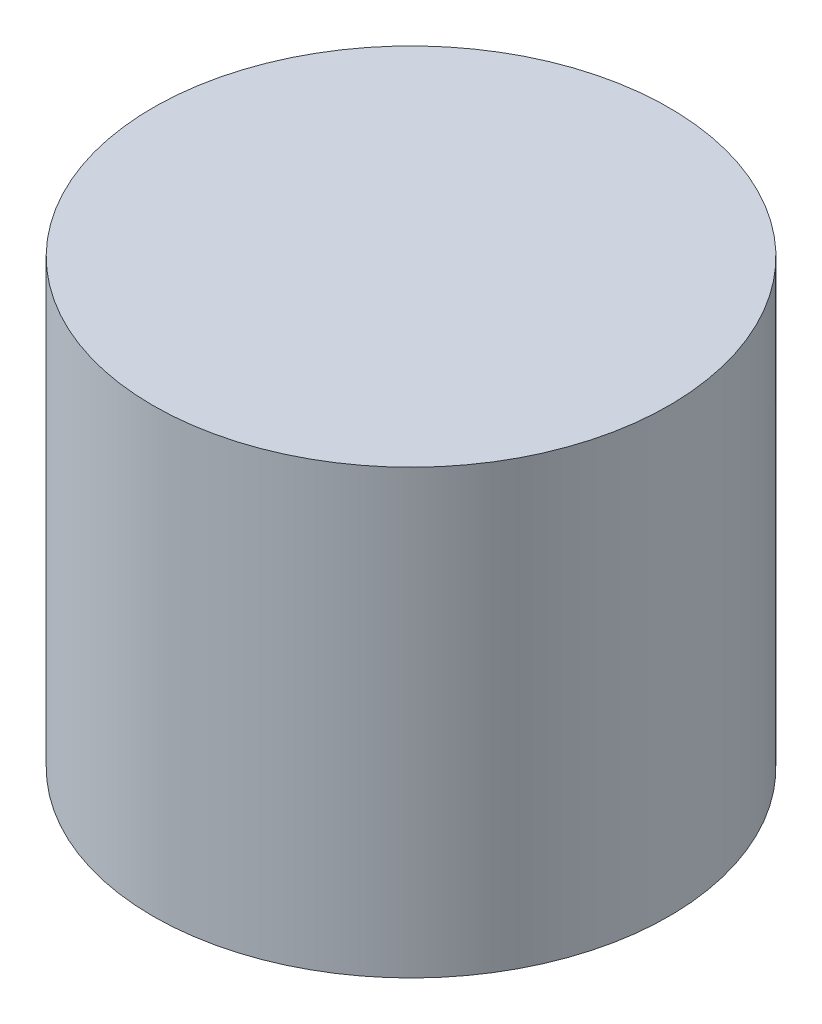
from build123d import *

# Parameters (mm, degrees)
SKETCH1_R           = 7
BOSS_EXTRUDE1_DEPTH = 12
CUT_EXTRUDE1_DEPTH  = 7


with BuildPart() as part:
    # Sketch1 → Boss-Extrude1 (new body)
    with BuildSketch(Plane(origin=(0, 0, 0), x_dir=(1, 0, 0), z_dir=(0, 1, 0))):
        Circle(SKETCH1_R)
    extrude(amount=BOSS_EXTRUDE1_DEPTH)

    # Sketch2 → Cut-Extrude1 (cut)
    with BuildSketch(Plane.XZ):
        with BuildLine():
            Line((-2.75, -1), (2.75, -1))
            ThreePointArc((2.75, -1), (0, 2.926174978), (-2.75, -1))
        make_face()
    extrude(amount=-CUT_EXTRUDE1_DEPTH, mode=Mode.SUBTRACT)


solid = part.part
